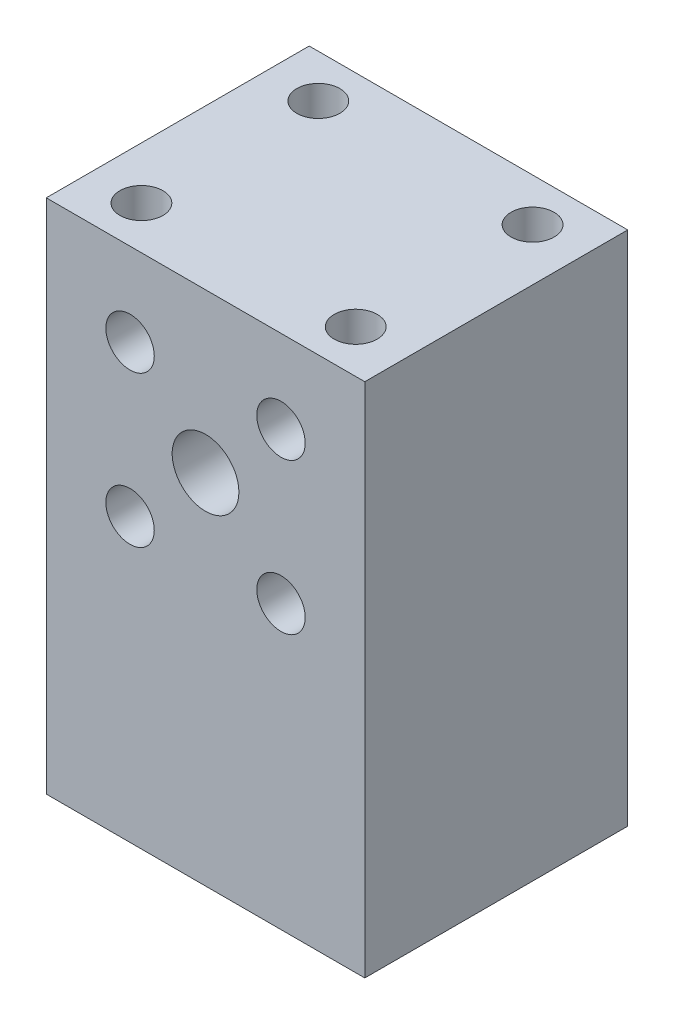
from build123d import *

# Parameters (mm, degrees)
SKETCH1_W           = 47
SKETCH1_H           = 38.8
BOSS_EXTRUDE1_DEPTH = 76.2
SKETCH2_R           = 3.571875
SKETCH2_R_2         = 4.92125
CUT_EXTRUDE1_DEPTH  = 98.574996797
SKETCH1_8_R         = 2.5
SKETCH1_8_R_2       = 2.627
CUT_EXTRUDE2_DEPTH  = 38.1
SKETCH4_R           = 9.525
CUT_EXTRUDE4_DEPTH  = 21.0185
SKETCH5_R           = 3.175
CUT_EXTRUDE5_DEPTH  = 6.35


with BuildPart() as part:
    # Sketch1 → Boss-Extrude1 (new body)
    with BuildSketch(Plane(origin=(0, 0, 0), x_dir=(1, 0, 0), z_dir=(0, 1, 0))):
        with Locations((23.5, 19.4)):
            Rectangle(SKETCH1_W, SKETCH1_H)
    extrude(amount=BOSS_EXTRUDE1_DEPTH)

    # Sketch2 → Cut-Extrude1 (cut, through all)
    with BuildSketch(Plane.XY):
        with Locations((34.63551759, 63.94291018)):
            Circle(SKETCH2_R)
        with Locations((34.63551759, 41.671875)):
            Circle(SKETCH2_R)
        with Locations((12.36448241, 41.671875)):
            Circle(SKETCH2_R)
        with Locations((12.36448241, 63.94291018)):
            Circle(SKETCH2_R)
        with Locations((23.5, 52.80739259)):
            Circle(SKETCH2_R_2)
    extrude(amount=-CUT_EXTRUDE1_DEPTH, mode=Mode.SUBTRACT)

    # Sketch1_8 → Cut-Extrude2 (cut)
    with BuildSketch(Plane(origin=(0, 0, 0), x_dir=(1, 0, 0), z_dir=(0, 1, 0))):
        with Locations((42.5, 34.4)):
            Circle(SKETCH1_8_R)
        with Locations((42.5, 4.4)):
            Circle(SKETCH1_8_R)
        with Locations((4.5, 4.4)):
            Circle(SKETCH1_8_R)
        with Locations((4.5, 34.4)):
            Circle(SKETCH1_8_R_2)
    extrude(amount=CUT_EXTRUDE2_DEPTH, mode=Mode.SUBTRACT)

    # Sketch4 → Cut-Extrude4 (cut)
    with BuildSketch(Plane(origin=(0, 0, -38.8), x_dir=(-1, 0, 0), z_dir=(0, 0, -1))):
        with Locations((-23.5, 52.80739259)):
            Circle(SKETCH4_R)
    extrude(amount=-CUT_EXTRUDE4_DEPTH, mode=Mode.SUBTRACT)

    # Sketch5 → Cut-Extrude5 (cut)
    with BuildSketch(Plane(origin=(0, 76.2, 0), x_dir=(1, 0, 0), z_dir=(0, 1, 0))):
        with Locations((7.692010309, 32.45)):
            Circle(SKETCH5_R)
        with Locations((39.307989691, 32.45)):
            Circle(SKETCH5_R)
        with Locations((39.307989691, 6.35)):
            Circle(SKETCH5_R)
        with Locations((7.692010309, 6.35)):
            Circle(SKETCH5_R)
    extrude(amount=-CUT_EXTRUDE5_DEPTH, mode=Mode.SUBTRACT)


solid = part.part
